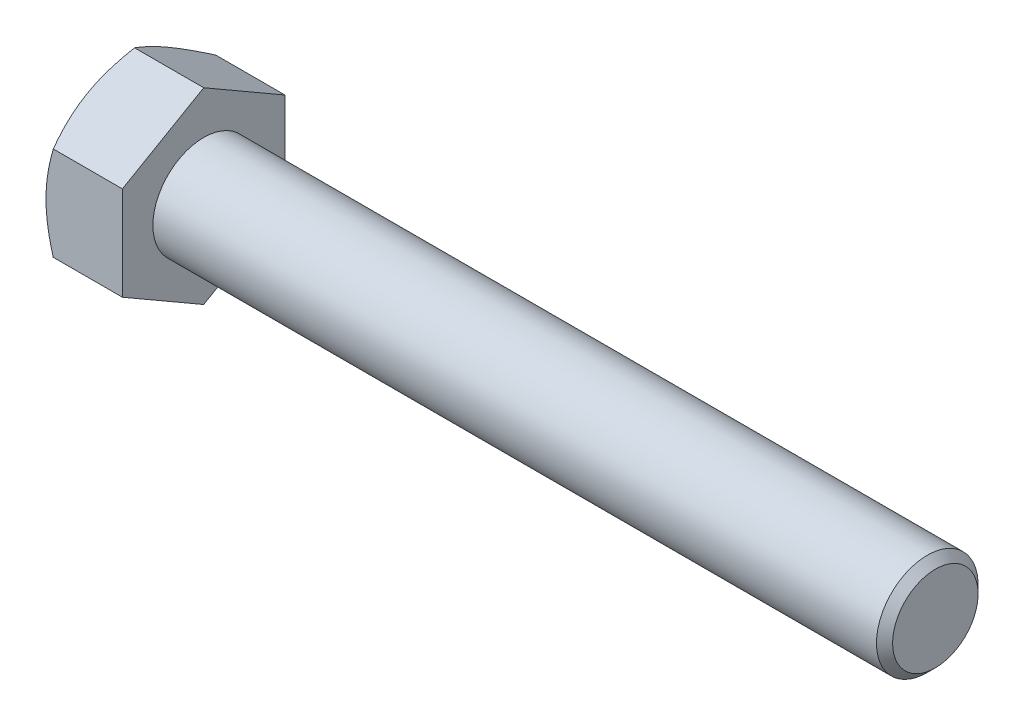
from build123d import *

# Parameters (mm, degrees)
BASEHEAD_DEPTH = 5.969


with BuildPart() as part:
    # Sketch1 → BaseHead (new body)
    with BuildSketch(Plane(origin=(0, 0, 0), x_dir=(0, 0, -1), z_dir=(1, 0, 0))):
        Polygon((6.35, 3.666174209), (6.35, -3.666174209), (0, -7.332348419), (-6.35, -3.666174209), (-6.35, 3.666174209), (0, 7.332348419), align=None)
    extrude(amount=BASEHEAD_DEPTH)

    # BodySke → BaseBody (revolve)
    with BuildSketch(Plane.XY):
        Polygon((0, 0), (63.119, 0), (63.119, 3.33883), (62.48908, 3.96875), (0, 3.96875), align=None)
    revolve(axis=Axis((0, 0, 0), (1, 0, 0)))

    # Sketch3 → HeadChamfer (revolve, cut)
    with BuildSketch(Plane.XY):
        Polygon((0, 6.35), (4.233333333, 13.682348419), (4.233333333, 20.032348419), (-12.7, 20.032348419), (-12.7, 6.35), align=None)
    revolve(axis=Axis((0, 0, 0), (1, 0, 0)), mode=Mode.SUBTRACT)


solid = part.part
